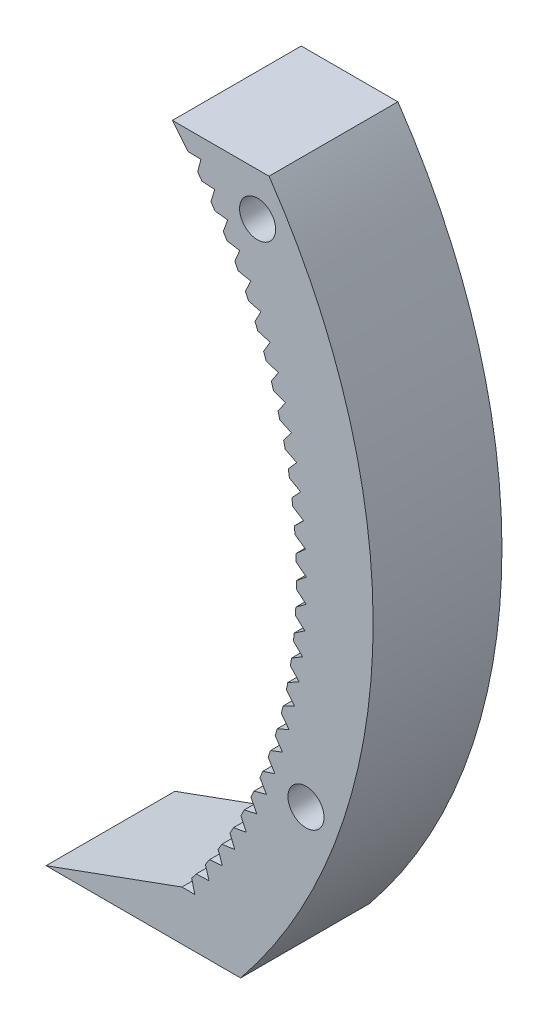
from build123d import *

# Parameters (mm, degrees)
SKETCH1_R                                 = 21.166666667
BOSS_EXTRUDE1_DEPTH                       = 12.7
CUT_EXTRUDE_DCLTBC_DEPTH                  = 13.7
FILLET_TIP_DCLTBC_R                       = 0.376401082
FILLET_ROOT_DCLTBC_R                      = 0.752802164
CIRPATTERN_DCLTBC_COUNT                   = 18
FILLET_TIP_DCLTBC_OF_CIRPATTERN_DCLTBC_R  = 0.376401082
FILLET_ROOT_DCLTBC_OF_CIRPATTERN_DCLTBC_R = 0.752802164
SKETCH4_R                                 = 3.556
CUT_EXTRUDE2_DEPTH                        = 13.7000001
SKETCH5_R                                 = 1
CUT_EXTRUDE3_DEPTH                        = 13.7000001
BOSS_EXTRUDE3_DEPTH                       = 12.7
SKETCH9_R                                 = 1.778
CUT_EXTRUDE4_DEPTH                        = 101.6
SKETCH10_R                                = 2.75
CUT_EXTRUDE5_DEPTH                        = 7.7
CUT_EXTRUDE6_DEPTH                        = 13.7000001
CIRPATTERN1_COUNT                         = 30
CIRPATTERN1_ANGLE                         = 75
SKETCH12_W                                = 54.92757211
SKETCH12_H                                = 48.855993121
CUT_EXTRUDE7_DEPTH                        = 13.7000001


with BuildPart() as part:
    # Sketch1 → Boss-Extrude1 (new body)
    with BuildSketch(Plane.XY):
        Circle(SKETCH1_R)
    extrude(amount=BOSS_EXTRUDE1_DEPTH)

    # DCLTBC → Cut-Extrude-DCLTBC (cut, through all)
    with BuildSketch(Plane.XY):
        with BuildLine():
            Line((-0.988599485, 17.23683661), (-0.939299003, 16.37725256))
            ThreePointArc((-0.939299003, 16.37725256), (0, 16.404166667), (0.939299003, 16.37725256))
            Line((0.939299003, 16.37725256), (0.988599485, 17.23683661))
            add(Edge.make_bspline(
                [(0.988599485, 17.23683661), (0.989063314, 17.24324115), (0.990661792, 17.261181979), (0.994858273, 17.295004515), (1.003369641, 17.350013815), (1.016655031, 17.419804647), (1.036619493, 17.509601098), (1.063718234, 17.614795353), (1.097234262, 17.729707804), (1.137709634, 17.85389969), (1.181621422, 17.977005275), (1.228695452, 18.099012466), (1.278527467, 18.219794849), (1.342341331, 18.365146152), (1.42364652, 18.538069209), (1.525589195, 18.738036686), (1.649316002, 18.962165854), (1.783980218, 19.187521629), (1.923498112, 19.406676656), (2.072405817, 19.624910262), (2.222105415, 19.833784741), (2.385586794, 20.047220122), (2.540566559, 20.242458208), (2.722891612, 20.457068476), (2.872582231, 20.629074977), (3.034353491, 20.803165616), (3.114136758, 20.887359483), (3.155350355, 20.930158669)],
                knots=[0, 0, 0, 0, 0, 0.005376749, 0.015083688, 0.02853182, 0.04661014, 0.064854849, 0.092110525, 0.119476176, 0.146842496, 0.174208854, 0.201574956, 0.228941013, 0.256307345, 0.307035032, 0.361767352, 0.416499661, 0.471231937, 0.525964282, 0.580696616, 0.635428982, 0.690161387, 0.744893688, 0.799626082, 0.854358408, 0.909090915, 0.909090915, 0.909090915, 0.909090915, 0.909090915], degree=4))
            ThreePointArc((3.155350355, 20.930158669), (0, 21.166666667), (-3.155350355, 20.930158669))
            add(Edge.make_bspline(
                [(-0.988599485, 17.23683661), (-0.989063314, 17.24324115), (-0.990661792, 17.261181979), (-0.994858273, 17.295004515), (-1.003369641, 17.350013815), (-1.016655031, 17.419804647), (-1.036619493, 17.509601098), (-1.063718234, 17.614795353), (-1.097234262, 17.729707804), (-1.137709634, 17.85389969), (-1.181621422, 17.977005275), (-1.228695452, 18.099012466), (-1.278527467, 18.219794849), (-1.342341331, 18.365146152), (-1.42364652, 18.538069209), (-1.525589195, 18.738036686), (-1.649316002, 18.962165854), (-1.783980218, 19.187521629), (-1.923498112, 19.406676656), (-2.072405817, 19.624910262), (-2.222105415, 19.833784741), (-2.385586794, 20.047220122), (-2.540566559, 20.242458208), (-2.722891612, 20.457068476), (-2.872582231, 20.629074977), (-3.034353491, 20.803165616), (-3.114136758, 20.887359483), (-3.155350355, 20.930158669)],
                knots=[0, 0, 0, 0, 0, 0.005376749, 0.015083688, 0.02853182, 0.04661014, 0.064854849, 0.092110525, 0.119476176, 0.146842496, 0.174208854, 0.201574956, 0.228941013, 0.256307345, 0.307035032, 0.361767352, 0.416499661, 0.471231937, 0.525964282, 0.580696616, 0.635428982, 0.690161387, 0.744893688, 0.799626082, 0.854358408, 0.909090915, 0.909090915, 0.909090915, 0.909090915, 0.909090915], degree=4))
        make_face()
    cut_extrude_dcltbc = extrude(amount=CUT_EXTRUDE_DCLTBC_DEPTH, mode=Mode.SUBTRACT)

    # Fillet-Tip-DCLTBC
    fillet_tip_dcltbc_edges = [part.edges().sort_by_distance(p)[0] for p in [
        (3.155350355, 20.930158669, 6.35),
        (-3.155350355, 20.930158669, 6.35),
    ]]
    fillet(fillet_tip_dcltbc_edges, radius=FILLET_TIP_DCLTBC_R)

    # Fillet-Root-DCLTBC
    fillet_root_dcltbc_edges = [part.edges().sort_by_distance(p)[0] for p in [
        (0.939299003, 16.37725256, 6.35),
        (-0.939299003, 16.37725256, 6.35),
    ]]
    fillet(fillet_root_dcltbc_edges, radius=FILLET_ROOT_DCLTBC_R)

    # CirPattern-DCLTBC: Cut-Extrude-DCLTBC ×18 about axis
    cirpattern_dcltbc_axis = Axis((0, 0, 12.7), (0, 0, 1))
    for i in range(1, CIRPATTERN_DCLTBC_COUNT):
        add(cut_extrude_dcltbc.rotate(cirpattern_dcltbc_axis, i * 360 / CIRPATTERN_DCLTBC_COUNT), mode=Mode.SUBTRACT)

    # Fillet-Tip-DCLTBC of CirPattern-DCLTBC
    fillet_tip_dcltbc_of_cirpattern_dcltbc_edges = [part.edges().sort_by_distance(p)[0] for p in [
        (-4.193476424, 20.747109034, 6.35),
        (-10.123595312, 18.588722273, 6.35),
        (-11.036508056, 18.061651854, 6.35),
        (-15.870785267, 14.00521163, 6.35),
        (-16.548373935, 13.1976929, 6.35),
        (-19.70372429, 7.73246577, 6.35),
        (-20.06426169, 6.741897404, 6.35),
        (-21.160103368, 0.527070418, 6.35),
        (-21.160103368, -0.527070418, 6.35),
        (-20.06426169, -6.741897404, 6.35),
        (-19.70372429, -7.73246577, 6.35),
        (-16.548373935, -13.1976929, 6.35),
        (-15.870785267, -14.00521163, 6.35),
        (-11.036508056, -18.061651854, 6.35),
        (-10.123595312, -18.588722273, 6.35),
        (-4.193476424, -20.747109034, 6.35),
        (-3.155350355, -20.930158669, 6.35),
        (3.155350355, -20.930158669, 6.35),
        (4.193476424, -20.747109034, 6.35),
        (10.123595312, -18.588722273, 6.35),
        (11.036508056, -18.061651854, 6.35),
        (15.870785267, -14.00521163, 6.35),
        (16.548373935, -13.1976929, 6.35),
        (19.70372429, -7.73246577, 6.35),
        (20.06426169, -6.741897404, 6.35),
        (21.160103368, -0.527070418, 6.35),
        (21.160103368, 0.527070418, 6.35),
        (20.06426169, 6.741897404, 6.35),
        (19.70372429, 7.73246577, 6.35),
        (16.548373935, 13.1976929, 6.35),
        (15.870785267, 14.00521163, 6.35),
        (11.036508056, 18.061651854, 6.35),
        (10.123595312, 18.588722273, 6.35),
        (4.193476424, 20.747109034, 6.35),
    ]]
    fillet(fillet_tip_dcltbc_of_cirpattern_dcltbc_edges, radius=FILLET_TIP_DCLTBC_OF_CIRPATTERN_DCLTBC_R)

    # Fillet-Root-DCLTBC of CirPattern-DCLTBC
    fillet_root_dcltbc_of_cirpattern_dcltbc_edges = [part.edges().sort_by_distance(p)[0] for p in [
        (-4.718697926, 15.710842559, 6.35),
        (-6.48400261, 15.0683242, 6.35),
        (-9.807550244, 13.149473078, 6.35),
        (-11.246639808, 11.941933556, 6.35),
        (-13.71346726, 9.002083078, 6.35),
        (-14.652766263, 7.375169482, 6.35),
        (-15.965337734, 3.768909003, 6.35),
        (-16.291552854, 1.918851122, 6.35),
        (-16.291552854, -1.918851122, 6.35),
        (-15.965337734, -3.768909003, 6.35),
        (-14.652766263, -7.375169482, 6.35),
        (-13.71346726, -9.002083078, 6.35),
        (-11.246639808, -11.941933556, 6.35),
        (-9.807550244, -13.149473078, 6.35),
        (-6.48400261, -15.0683242, 6.35),
        (-4.718697926, -15.710842559, 6.35),
        (-0.939299003, -16.37725256, 6.35),
        (0.939299003, -16.37725256, 6.35),
        (4.718697926, -15.710842559, 6.35),
        (6.48400261, -15.0683242, 6.35),
        (9.807550244, -13.149473078, 6.35),
        (11.246639808, -11.941933556, 6.35),
        (13.71346726, -9.002083078, 6.35),
        (14.652766263, -7.375169482, 6.35),
        (15.965337734, -3.768909003, 6.35),
        (16.291552854, -1.918851122, 6.35),
        (16.291552854, 1.918851122, 6.35),
        (15.965337734, 3.768909003, 6.35),
        (14.652766263, 7.375169482, 6.35),
        (13.71346726, 9.002083078, 6.35),
        (11.246639808, 11.941933556, 6.35),
        (9.807550244, 13.149473078, 6.35),
        (6.48400261, 15.0683242, 6.35),
        (4.718697926, 15.710842559, 6.35),
    ]]
    fillet(fillet_root_dcltbc_of_cirpattern_dcltbc_edges, radius=FILLET_ROOT_DCLTBC_OF_CIRPATTERN_DCLTBC_R)

    # Sketch4 → Cut-Extrude2 (cut, through all)
    with BuildSketch(Plane.XY.offset(12.7)):
        Circle(SKETCH4_R)
    extrude(amount=-CUT_EXTRUDE2_DEPTH, mode=Mode.SUBTRACT)

    # Sketch5 → Cut-Extrude3 (cut, through all)
    with BuildSketch(Plane.XY.offset(12.7)):
        with Locations((-7, 0)):
            Circle(SKETCH5_R)
        with Locations((0, 7)):
            Circle(SKETCH5_R)
        with Locations((7, 0)):
            Circle(SKETCH5_R)
        with Locations((0, -7)):
            Circle(SKETCH5_R)
    extrude(amount=-CUT_EXTRUDE3_DEPTH, mode=Mode.SUBTRACT)

    # Sketch7 → Boss-Extrude3 (add, through all)
    with BuildSketch(Plane.XY.offset(12.7)):
        with BuildLine():
            Line((6.35, -14.113720517), (6.35, -26.813720517))
            ThreePointArc((6.35, -26.813720517), (16.563553869, -62.204697552), (3.547653041, -96.663720517))
            Line((3.547653041, -96.663720517), (-15.629346959, -96.663720517))
            Line((-15.629346959, -96.663720517), (-2.2365023, -91.788432197))
            ThreePointArc((-2.2365023, -91.788432197), (9.041883703, -59.131392983), (-3.175, -26.813720517))
            Line((-3.175, -26.813720517), (-3.175, -14.113720517))
            Line((-3.175, -14.113720517), (6.35, -14.113720517))
        make_face()
    extrude(amount=-BOSS_EXTRUDE3_DEPTH)

    # Sketch9 → Cut-Extrude4 (cut)
    with BuildSketch(Plane.XY.offset(12.7)):
        with Locations((5.222816577, -31.033083261)):
            Circle(SKETCH9_R)
        with Locations((9.993601717, -78.846696124)):
            Circle(SKETCH9_R)
    extrude(amount=-CUT_EXTRUDE4_DEPTH, mode=Mode.SUBTRACT)

    # Sketch10 → Cut-Extrude5 (cut)
    with BuildSketch(Plane.XY.offset(12.7)):
        with Locations((-7, 0)):
            Circle(SKETCH10_R)
        with Locations((0, -7)):
            Circle(SKETCH10_R)
        with Locations((7, 0)):
            Circle(SKETCH10_R)
        with Locations((0, 7)):
            Circle(SKETCH10_R)
    extrude(amount=-CUT_EXTRUDE5_DEPTH, mode=Mode.SUBTRACT)

    # Sketch11 → Cut-Extrude6 (cut, through all)
    with BuildSketch(Plane.XY.offset(12.7)):
        with BuildLine():
            Line((-2.2365023, -91.788432197), (-0.9665023, -91.788432197))
            Line((-0.9665023, -91.788432197), (-1.271582988, -90.555620056))
            ThreePointArc((-1.271582988, -90.555620056), (-1.749293325, -91.175743408), (-2.2365023, -91.788432197))
        make_face()
    cut_extrude6 = extrude(amount=-CUT_EXTRUDE6_DEPTH, mode=Mode.SUBTRACT)

    # CirPattern1: Cut-Extrude6 ×30 about axis
    cirpattern1_axis = Axis((-41.752817912, -59.865073971, 0), (0, 0, 1))
    for i in range(1, CIRPATTERN1_COUNT):
        add(cut_extrude6.rotate(cirpattern1_axis, i * CIRPATTERN1_ANGLE / (CIRPATTERN1_COUNT - 1)), mode=Mode.SUBTRACT)

    # Sketch12 → Cut-Extrude7 (cut, through all)
    with BuildSketch(Plane.XY.offset(12.7)):
        with Locations((1.598076801, -2.385723956)):
            Rectangle(SKETCH12_W, SKETCH12_H)
    extrude(amount=-CUT_EXTRUDE7_DEPTH, mode=Mode.SUBTRACT)


solid = part.part
